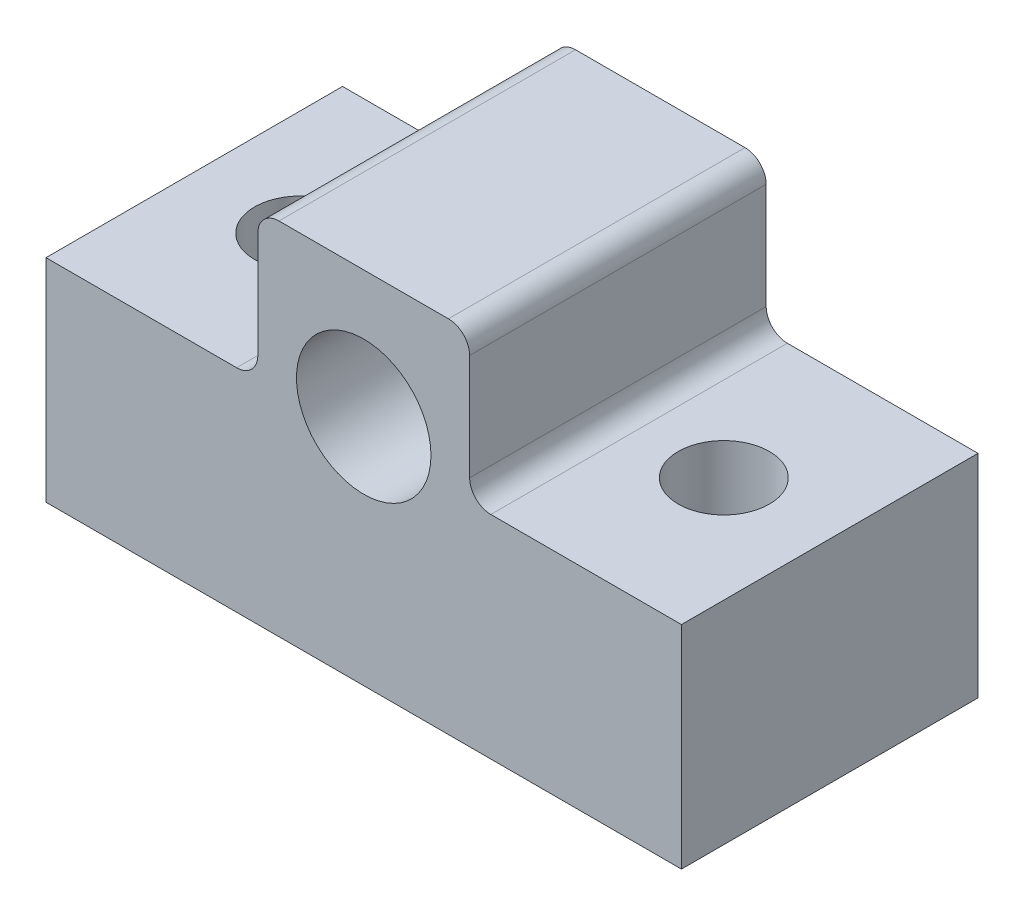
from build123d import *

# Parameters (mm, degrees)
SKETCH1_W             = 30
SKETCH1_H             = 52
BASE_EXTRUDE_DEPTH    = 7
SKETCH2_W             = 30
SKETCH2_H             = 35
CUT_EXTRUDE1_DEPTH    = 15
SKETCH3_R             = 3.175
CUT_EXTRUDE2_DEPTH    = 15
F_8_CLEARANCE_HOLE1_D = 4.3053
SKETCH6_W             = 10
SKETCH6_H             = 14
CUT_EXTRUDE3_DEPTH    = 7
FILLET1_R             = 1


with BuildPart() as part:
    # Sketch1 → Base-Extrude (new body, symmetric)
    with BuildSketch(Plane.XY):
        Rectangle(SKETCH1_W, SKETCH1_H)
    extrude(amount=BASE_EXTRUDE_DEPTH, both=True)

    # Sketch2 → Cut-Extrude1 (cut, through all)
    with BuildSketch(Plane.XY.offset(7)):
        with Locations((0, 8.5)):
            Rectangle(SKETCH2_W, SKETCH2_H)
    extrude(amount=-CUT_EXTRUDE1_DEPTH, mode=Mode.SUBTRACT)

    # Sketch3 → Cut-Extrude2 (cut, through all)
    with BuildSketch(Plane.XY.offset(7)):
        with Locations((0, -15)):
            Circle(SKETCH3_R)
    extrude(amount=-CUT_EXTRUDE2_DEPTH, mode=Mode.SUBTRACT)

    # #8 Clearance Hole1 (through all)
    with Locations(Plane(origin=(-8.315488936, -9, -4.532476802), x_dir=(-1, 0, 0), z_dir=(0, 1, 0))):
        with Locations((-18.315488936, 4.532476802), (1.684511064, 4.532476802)):
            Hole(F_8_CLEARANCE_HOLE1_D / 2)

    # Sketch6 → Cut-Extrude3 (cut)
    with BuildSketch(Plane(origin=(0, -9, 0), x_dir=(-1, 0, 0), z_dir=(0, 1, 0))):
        with Locations((10, 0)):
            Rectangle(SKETCH6_W, SKETCH6_H)
        with Locations((-10, 0)):
            Rectangle(SKETCH6_W, SKETCH6_H)
    extrude(amount=-CUT_EXTRUDE3_DEPTH, mode=Mode.SUBTRACT)

    # Fillet1
    fillet1_edges = [part.edges().sort_by_distance(p)[0] for p in [
        (-5, -9, 0),
        (-5, -16, 0),
        (5, -9, 0),
        (5, -16, 0),
    ]]
    fillet(fillet1_edges, radius=FILLET1_R)


solid = part.part
